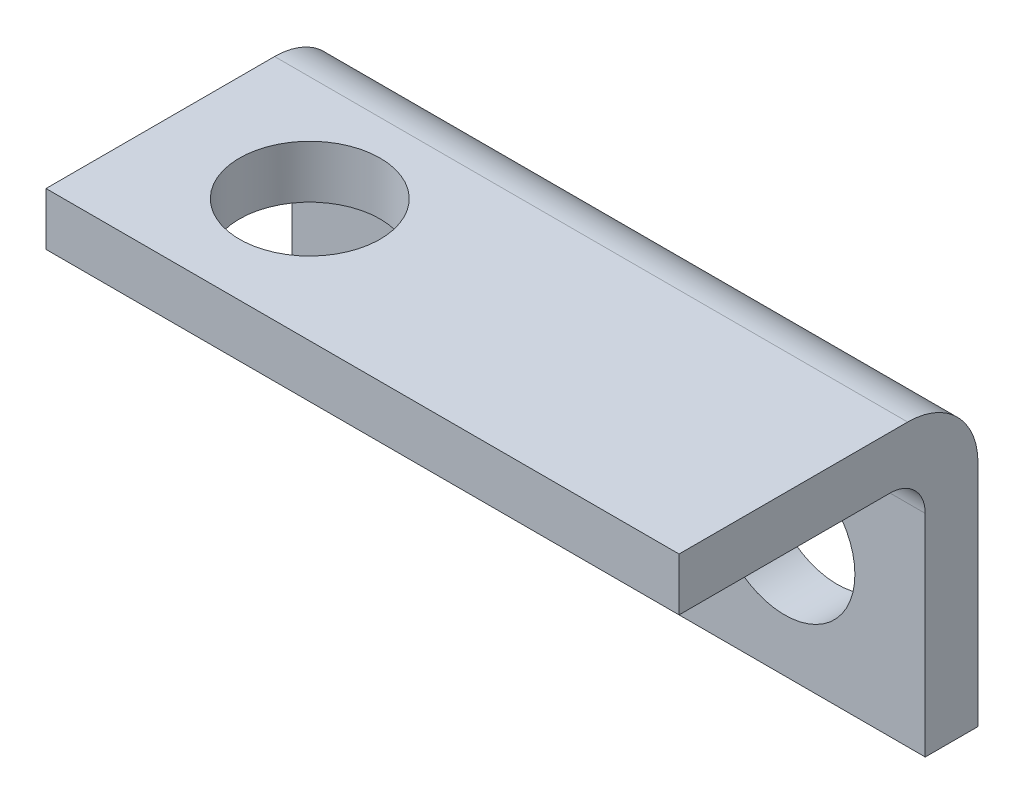
from build123d import *

# Parameters (mm, degrees)
SKETCH1_W           = 36
SKETCH1_H           = 17
BOSS_EXTRUDE1_DEPTH = 3
SKETCH15_W          = 36
SKETCH15_H          = 3
BOSS_EXTRUDE2_DEPTH = 14
FILLET2_R           = 2
FILLET3_R           = 4
SKETCH17_R          = 4
CUT_EXTRUDE1_DEPTH  = 18
SKETCH18_R          = 4
CUT_EXTRUDE2_DEPTH  = 18


with BuildPart() as part:
    # Sketch1 → Boss-Extrude1 (new body)
    with BuildSketch(Plane.XY):
        Rectangle(SKETCH1_W, SKETCH1_H)
    extrude(amount=BOSS_EXTRUDE1_DEPTH)

    # Sketch15 → Boss-Extrude2 (add)
    with BuildSketch(Plane.XY.offset(3)):
        with Locations((0, 7)):
            Rectangle(SKETCH15_W, SKETCH15_H)
    extrude(amount=BOSS_EXTRUDE2_DEPTH)

    # Fillet2
    fillet2_edges = [part.edges().sort_by_distance(p)[0] for p in [
        (0, 5.5, 3),
    ]]
    fillet(fillet2_edges, radius=FILLET2_R)

    # Fillet3
    fillet3_edges = [part.edges().sort_by_distance(p)[0] for p in [
        (0, 8.5, 0),
    ]]
    fillet(fillet3_edges, radius=FILLET3_R)

    # Sketch17 → Cut-Extrude1 (cut, through all)
    with BuildSketch(Plane.XZ.offset(8.5)):
        with Locations((-10, 10)):
            Circle(SKETCH17_R)
    extrude(amount=-CUT_EXTRUDE1_DEPTH, mode=Mode.SUBTRACT)

    # Sketch18 → Cut-Extrude2 (cut, through all)
    with BuildSketch(Plane.XY.offset(17)):
        with Locations((10, -1.5)):
            Circle(SKETCH18_R)
    extrude(amount=-CUT_EXTRUDE2_DEPTH, mode=Mode.SUBTRACT)


solid = part.part
